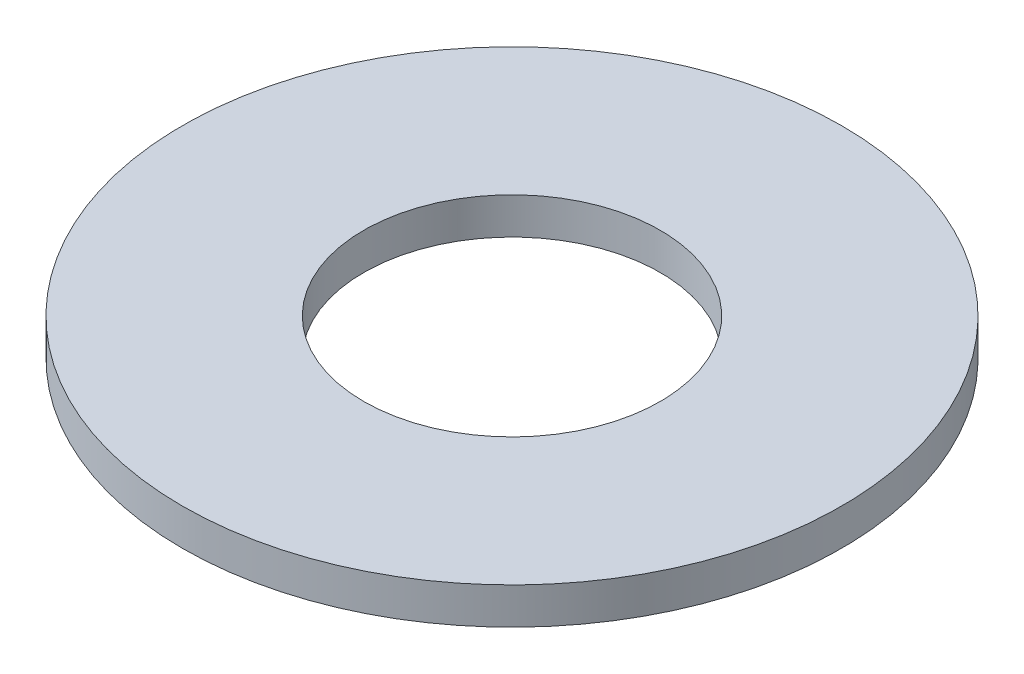
from build123d import *

# Parameters (mm, degrees)
SKETCH1_R           = 9
SKETCH1_R_2         = 4.05
BOSS_EXTRUDE1_DEPTH = 1


with BuildPart() as part:
    # Sketch1 → Boss-Extrude1 (new body)
    with BuildSketch(Plane(origin=(0, 0, 0), x_dir=(1, 0, 0), z_dir=(0, 1, 0))):
        Circle(SKETCH1_R)
        Circle(SKETCH1_R_2, mode=Mode.SUBTRACT)
    extrude(amount=BOSS_EXTRUDE1_DEPTH)


solid = part.part
